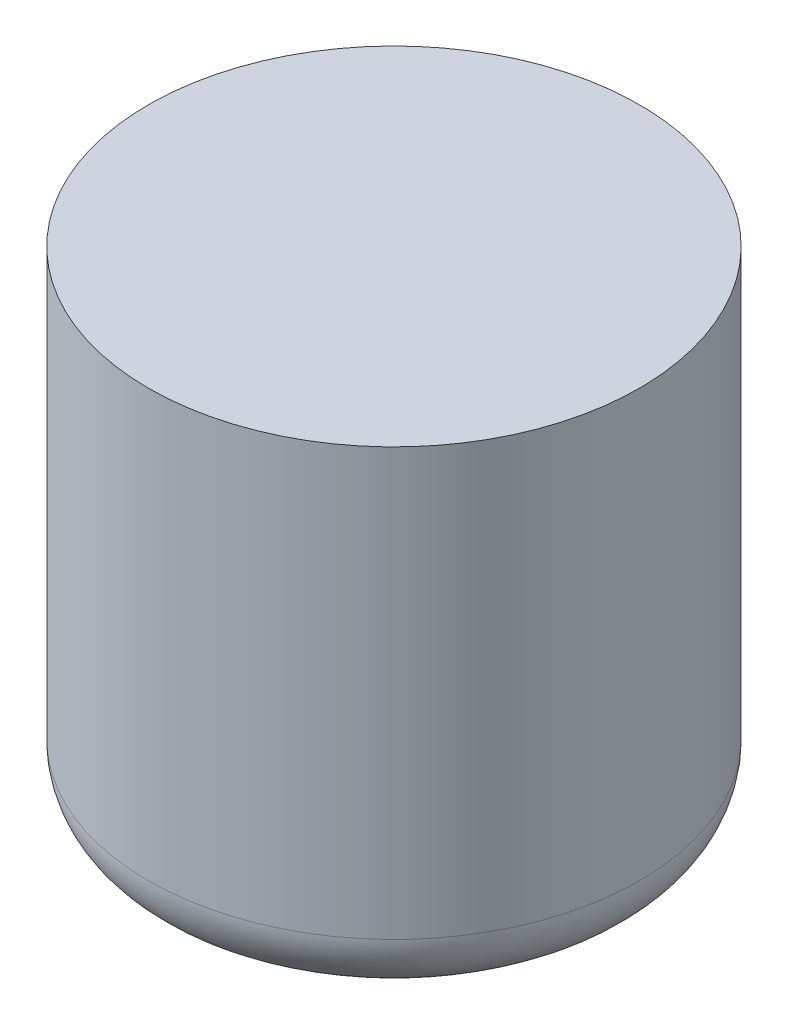
from build123d import *

# Parameters (mm, degrees)
SKETCH1_R           = 19.05
BOSS_EXTRUDE1_DEPTH = 38.1
FILLET1_R           = 5


with BuildPart() as part:
    # Sketch1 → Boss-Extrude1 (new body)
    with BuildSketch(Plane(origin=(0, 0, 0), x_dir=(1, 0, 0), z_dir=(0, 1, 0))):
        Circle(SKETCH1_R)
    extrude(amount=BOSS_EXTRUDE1_DEPTH)

    # Fillet1
    fillet1_edges = [part.edges().sort_by_distance(p)[0] for p in [
        (-19.05, 0, 0),
    ]]
    fillet(fillet1_edges, radius=FILLET1_R)


solid = part.part
